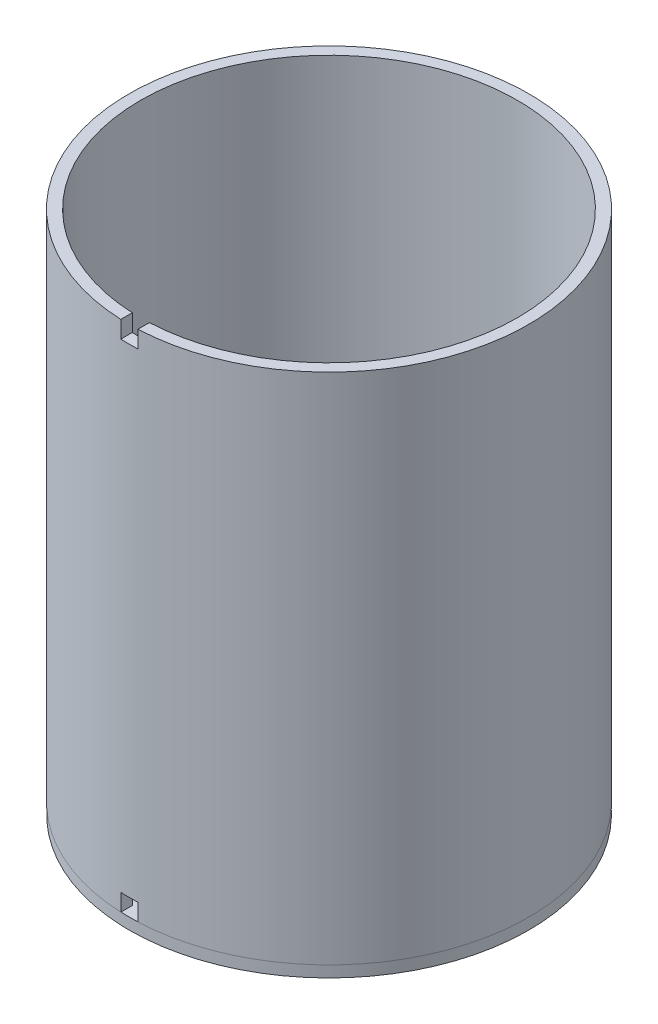
from build123d import *

# Parameters (mm, degrees)
SKETCH1_R           = 88.9
SKETCH1_R_2         = 38.1
BOSS_EXTRUDE1_DEPTH = 5.08
SKETCH2_R           = 88.969872842
SKETCH2_R_2         = 83.889872842
BOSS_EXTRUDE2_DEPTH = 228.6
SKETCH3_W           = 7.62
SKETCH3_H           = 7.62
CUT_EXTRUDE1_DEPTH  = 89.969872842


with BuildPart() as part:
    # Sketch1 → Boss-Extrude1 (new body)
    with BuildSketch(Plane(origin=(0, 0, 0), x_dir=(1, 0, 0), z_dir=(0, 1, 0))):
        Circle(SKETCH1_R)
        Circle(SKETCH1_R_2, mode=Mode.SUBTRACT)
    extrude(amount=BOSS_EXTRUDE1_DEPTH)

    # Sketch2 → Boss-Extrude2 (add)
    with BuildSketch(Plane(origin=(0, 5.08, 0), x_dir=(1, 0, 0), z_dir=(0, 1, 0))):
        Circle(SKETCH2_R)
        Circle(SKETCH2_R_2, mode=Mode.SUBTRACT)
    extrude(amount=BOSS_EXTRUDE2_DEPTH)

    # Sketch3 → Cut-Extrude1 (cut, through all)
    with BuildSketch(Plane.XY):
        with Locations((0, 229.87)):
            Rectangle(SKETCH3_W, SKETCH3_H)
        with Locations((0, 8.89)):
            Rectangle(SKETCH3_W, SKETCH3_H)
    extrude(amount=CUT_EXTRUDE1_DEPTH, mode=Mode.SUBTRACT)


solid = part.part
